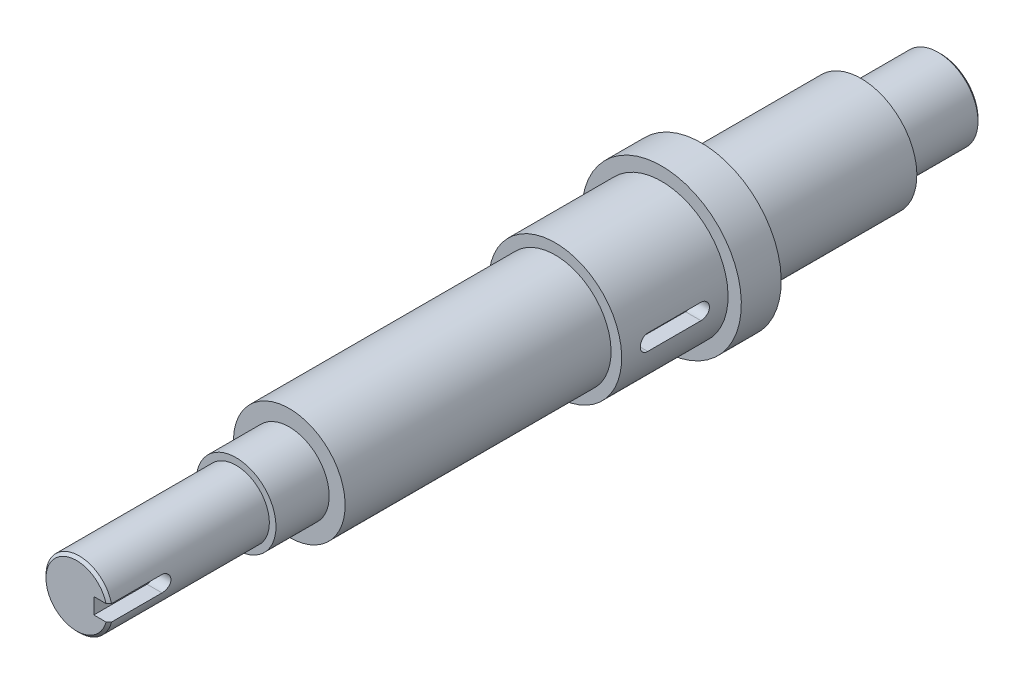
from build123d import *

# Parameters (mm, degrees)
M8X1_0_TAPPED_HOLE1_D     = 7
M8X1_0_TAPPED_HOLE1_DEPTH = 19
M8X1_0_TAPPED_HOLE1_TIP   = 2.103012167
CUT_EXTRUDE3_DEPTH        = 6
CUT_EXTRUDE4_DEPTH        = 6
CHAMFER1_SIZE             = 1
FILLET1_R                 = 1


with BuildPart() as part:
    # Sketch2 → Revolve1 (revolve)
    with BuildSketch(Plane(origin=(0, 0, 0), x_dir=(0, 0, -1), z_dir=(1, 0, 0))):
        Polygon((-225, 12.5), (-225, 0), (100, 0), (100, 15), (70, 15), (70, 21), (10, 21), (10, 30), (-5, 30), (-5, 25), (-45, 25), (-45, 21), (-145, 21), (-145, 15), (-165, 15), (-165, 12.5), align=None)
    revolve(axis=Axis((0, 0, 225), (0, 0, -1)))

    # M8x1.0 Tapped Hole1
    with Locations(Plane(origin=(0, 0, -100), x_dir=(0, -1, 0), z_dir=(0, 0, -1))):
        with Locations((0, 0)):
            Hole(M8X1_0_TAPPED_HOLE1_D / 2, depth=M8X1_0_TAPPED_HOLE1_DEPTH)
            with Locations((0, 0, -(M8X1_0_TAPPED_HOLE1_DEPTH + M8X1_0_TAPPED_HOLE1_TIP / 2))):  # 118° drill point
                Cone(0, M8X1_0_TAPPED_HOLE1_D / 2, M8X1_0_TAPPED_HOLE1_TIP, mode=Mode.SUBTRACT)

    # Sketch4 → Cut-Extrude3 (cut)
    with BuildSketch(Plane(origin=(12.5, 0, 0), x_dir=(0, 0, -1), z_dir=(1, 0, 0))):
        with BuildLine():
            Line((-205, 3), (-225, 3))
            Line((-225, 3), (-225, -3))
            Line((-225, -3), (-205, -3))
            ThreePointArc((-205, -3), (-202, 0), (-205, 3))
        make_face()
    extrude(amount=-CUT_EXTRUDE3_DEPTH, mode=Mode.SUBTRACT)

    # Sketch5 → Cut-Extrude4 (cut)
    with BuildSketch(Plane(origin=(25, 0, 0), x_dir=(0, 0, -1), z_dir=(1, 0, 0))):
        with BuildLine():
            Line((-35, 3), (-15, 3))
            ThreePointArc((-15, 3), (-12, 0), (-15, -3))
            Line((-15, -3), (-35, -3))
            ThreePointArc((-35, -3), (-38, 0), (-35, 3))
        make_face()
    extrude(amount=-CUT_EXTRUDE4_DEPTH, mode=Mode.SUBTRACT)

    # Chamfer1
    chamfer1_edges = [part.edges().sort_by_distance(p)[0] for p in [
        (0, -15, -100),
        (-9.842509843, -7.705517504, 225),
    ]]
    chamfer(chamfer1_edges, length=CHAMFER1_SIZE)

    # Fillet1
    fillet1_edges = [part.edges().sort_by_distance(p)[0] for p in [
        (0, -15, -70),
    ]]
    fillet(fillet1_edges, radius=FILLET1_R)


solid = part.part
